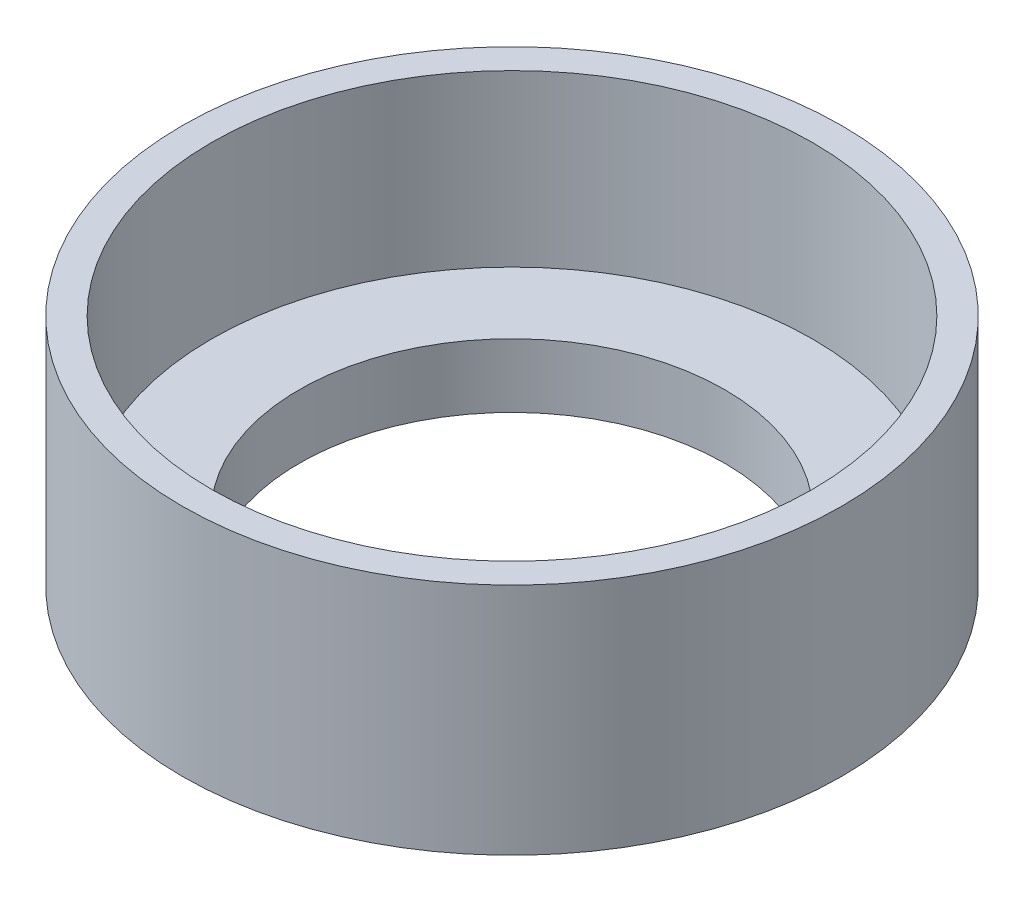
from build123d import *

# Parameters (mm, degrees)
SKETCH1_R           = 15.5
SKETCH1_R_2         = 14.125
BOSS_EXTRUDE1_DEPTH = 8
SKETCH2_R           = 15.5
SKETCH2_R_2         = 10
BOSS_EXTRUDE3_DEPTH = 3


with BuildPart() as part:
    # Sketch1 → Boss-Extrude1 (new body)
    with BuildSketch(Plane(origin=(0, 0, 0), x_dir=(1, 0, 0), z_dir=(0, 1, 0))):
        Circle(SKETCH1_R)
        Circle(SKETCH1_R_2, mode=Mode.SUBTRACT)
    extrude(amount=BOSS_EXTRUDE1_DEPTH)

    # Sketch2 → Boss-Extrude3 (add)
    with BuildSketch(Plane.XZ):
        Circle(SKETCH2_R)
        Circle(SKETCH2_R_2, mode=Mode.SUBTRACT)
    extrude(amount=BOSS_EXTRUDE3_DEPTH)


solid = part.part
